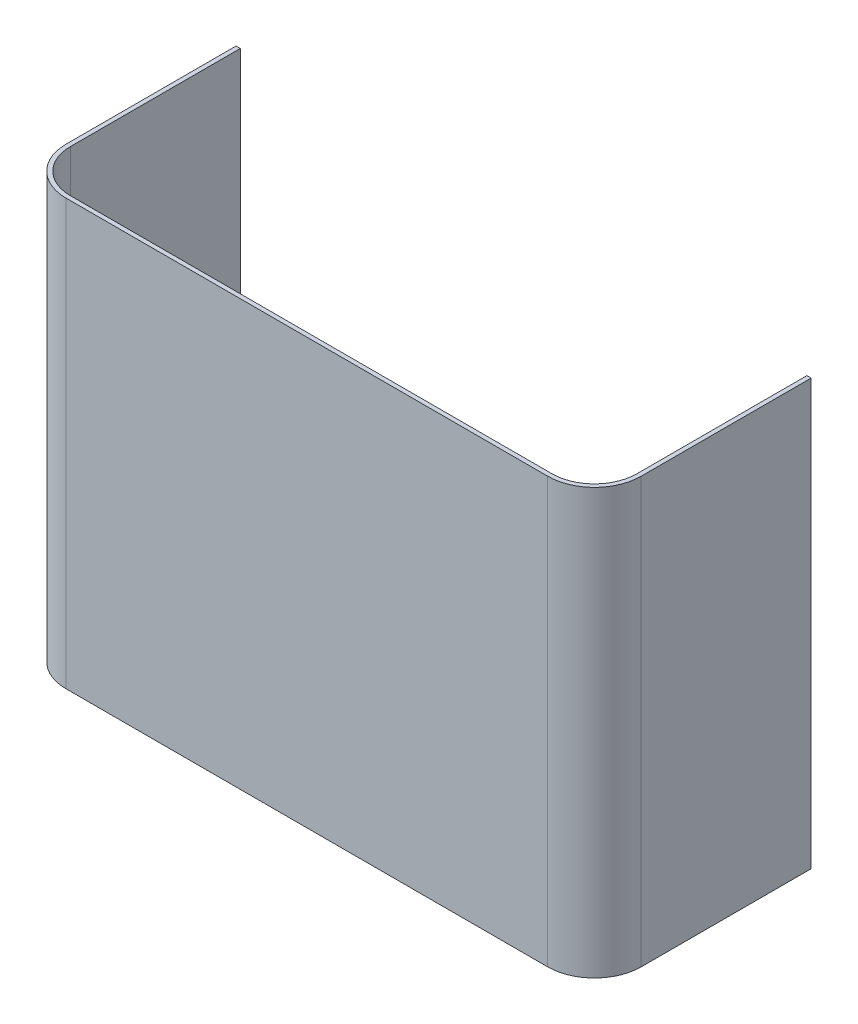
from build123d import *

# Parameters (mm, degrees)
SKETCH4_W          = 722.984552569
SKETCH4_H          = 1077.767689397
CUT_EXTRUDE1_DEPTH = 3


with BuildPart() as part:
    # Sweep-Thin1: sweep along a path in Sketch3
    with BuildLine(Plane(origin=(0, 0, 0), x_dir=(0, 0, -1), z_dir=(1, 0, 0))) as sweep_thin1_path:
        Line((0, 0), (0, 300))
    # Sketch1 → Sweep-Thin1 (sweep)
    with BuildSketch(Plane(origin=(0, 0, 0), x_dir=(1, 0, 0), z_dir=(0, 1, 0))):
        with BuildLine():
            Line((-170, -78), (170, -78))
            ThreePointArc((170, -78), (193.334523779, -68.334523779), (203, -45))
            Line((203, -45), (203, 78))
            Line((203, 78), (-203, 78))
            Line((-203, 78), (-203, -45))
            ThreePointArc((-203, -45), (-193.334523779, -68.334523779), (-170, -78))
        make_face()
        with BuildLine():
            Line((-170, -75), (170, -75))
            ThreePointArc((170, -75), (191.213203436, -66.213203436), (200, -45))
            Line((200, -45), (200, 75))
            Line((200, 75), (-200, 75))
            Line((-200, 75), (-200, -45))
            ThreePointArc((-200, -45), (-191.213203436, -66.213203436), (-170, -75))
        make_face(mode=Mode.SUBTRACT)
    sweep(path=sweep_thin1_path.line)

    # Sketch4 → Cut-Extrude1 (cut)
    with BuildSketch(Plane(origin=(0, 0, -78), x_dir=(-1, 0, 0), z_dir=(0, 0, -1))):
        with Locations((86.276452511, -157.075497452)):
            Rectangle(SKETCH4_W, SKETCH4_H)
    extrude(amount=-CUT_EXTRUDE1_DEPTH, mode=Mode.SUBTRACT)


solid = part.part
